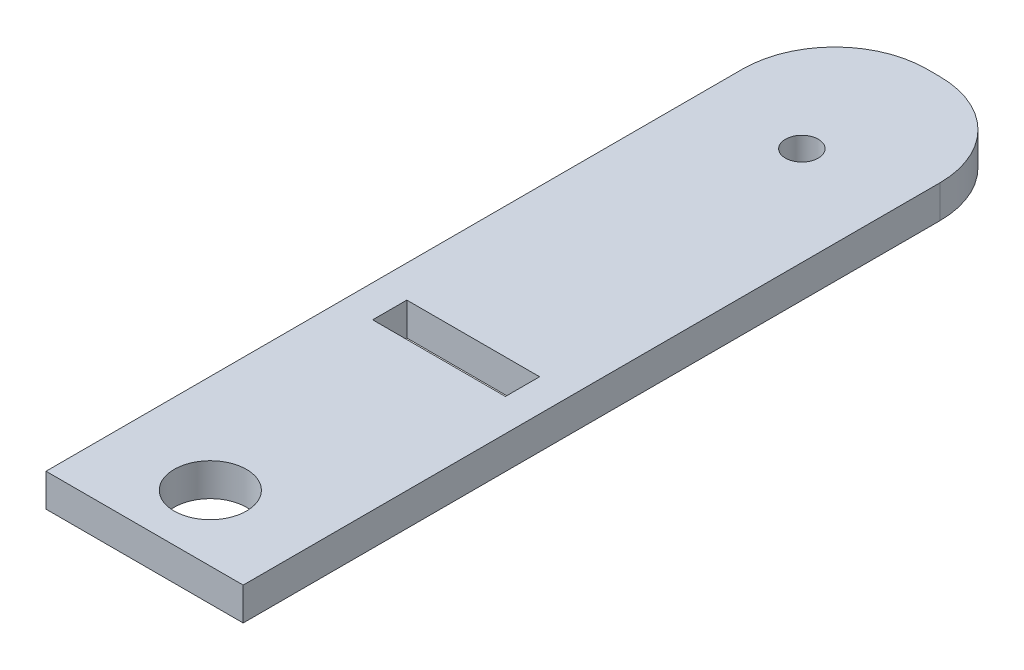
from build123d import *

# Parameters (mm, degrees)
SKETCH1_W           = 19.05
SKETCH1_H           = 76.2
SKETCH1_R           = 1.5875
SKETCH1_R_2         = 3.4925
SKETCH1_W_2         = 12.827
SKETCH1_H_2         = 3.302
BOSS_EXTRUDE1_DEPTH = 3.175
FILLET1_R           = 8.89
FILLET2_R           = 8.89


with BuildPart() as part:
    # Sketch1 → Boss-Extrude1 (new body)
    with BuildSketch(Plane(origin=(0, 0, 0), x_dir=(1, 0, 0), z_dir=(0, 1, 0))):
        Rectangle(SKETCH1_W, SKETCH1_H)
        with Locations((0, 25.4)):
            Circle(SKETCH1_R, mode=Mode.SUBTRACT)
        with Locations((0, -31.75)):
            Circle(SKETCH1_R_2, mode=Mode.SUBTRACT)
        with Locations((0, -8.001)):
            Rectangle(SKETCH1_W_2, SKETCH1_H_2, mode=Mode.SUBTRACT)
    extrude(amount=BOSS_EXTRUDE1_DEPTH)

    # Fillet1
    fillet1_edges = [part.edges().sort_by_distance(p)[0] for p in [
        (9.525, 1.5875, -38.1),
    ]]
    fillet(fillet1_edges, radius=FILLET1_R)

    # Fillet2
    fillet2_edges = [part.edges().sort_by_distance(p)[0] for p in [
        (-9.525, 1.5875, -38.1),
    ]]
    fillet(fillet2_edges, radius=FILLET2_R)


solid = part.part
